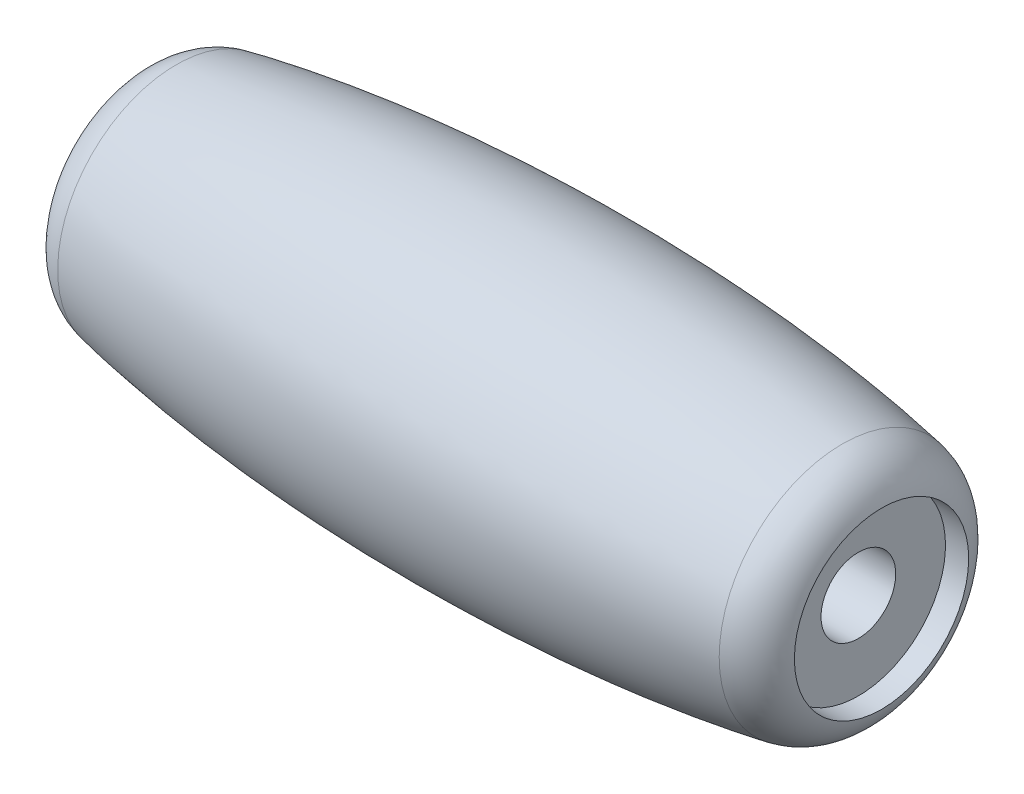
from build123d import *

# Parameters (mm, degrees)
SKETCH2_R          = 1.5
CUT_EXTRUDE1_DEPTH = 31
SKETCH3_R          = 3.5
SKETCH3_R_2        = 1.5
CUT_EXTRUDE2_DEPTH = 1


with BuildPart() as part:
    # Sketch1 → Revolve5 (revolve)
    with BuildSketch(Plane.XY):
        with BuildLine():
            Line((-15.473870067, 0), (14.526129933, 0))
            Line((14.526129933, 0), (14.526129933, 2.977982181))
            ThreePointArc((14.526129933, 2.977982181), (14.061170532, 4.260031462), (12.882479574, 4.945979877))
            add(Edge.make_bspline(
                [(12.882479574, 4.945979877), (-0.755720694, 7.415478586), (-13.871264836, 4.756435317)],
                knots=[0.969017626, 0.969017626, 0.969017626, 2.226302938, 2.226302938, 2.226302938], degree=2, weights=[1, 0.808826436, 1]))
            ThreePointArc((-13.871264836, 4.756435317), (-15.022222343, 4.062253989), (-15.473870067, 2.796313536))
            Line((-15.473870067, 2.796313536), (-15.473870067, 0))
        make_face()
    revolve(axis=Axis((-15.473870067, 0, 0), (1, 0, 0)))

    # Sketch2 → Cut-Extrude1 (cut, through all)
    with BuildSketch(Plane(origin=(14.526129933, 0, 0), x_dir=(0, 0, -1), z_dir=(1, 0, 0))):
        Circle(SKETCH2_R)
    extrude(amount=-CUT_EXTRUDE1_DEPTH, mode=Mode.SUBTRACT)

    # Sketch3 → Cut-Extrude2 (cut)
    with BuildSketch(Plane(origin=(14.526129933, 0, 0), x_dir=(0, 0, -1), z_dir=(1, 0, 0))):
        Circle(SKETCH3_R)
        Circle(SKETCH3_R_2, mode=Mode.SUBTRACT)
    cut_extrude2 = extrude(amount=-CUT_EXTRUDE2_DEPTH, mode=Mode.SUBTRACT)

    # Mirror1: Cut-Extrude2 across plane
    add(cut_extrude2.mirror(Plane(origin=(-0.473870067, 0, 0), x_dir=(0, 0, 1), z_dir=(1, 0, 0))), mode=Mode.SUBTRACT)


solid = part.part
